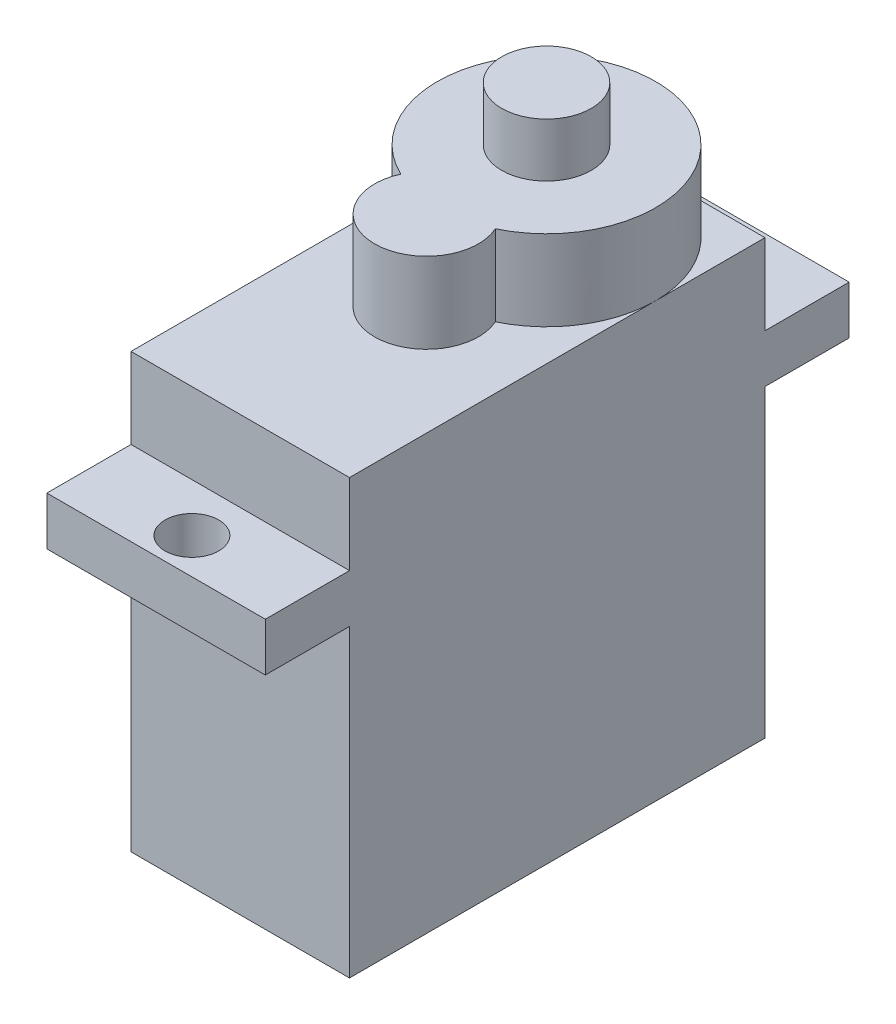
from build123d import *

# Parameters (mm, degrees)
SKETCH1_W           = 12.2
SKETCH1_H           = 23.2
BOSS_EXTRUDE3_DEPTH = 24.2
SKETCH5_W           = 12.2
SKETCH5_H           = 2.7
BOSS_EXTRUDE4_DEPTH = 4.7
CUT_EXTRUDE4_START  = -20.7
SKETCH6_R           = 1.5
CUT_EXTRUDE4_DEPTH  = 26.2
SKETCH7_R           = 2.9
SKETCH7_R_2         = 6.1
BOSS_EXTRUDE5_DEPTH = 4.5
SKETCH8_R           = 2.5
BOSS_EXTRUDE6_DEPTH = 3


with BuildPart() as part:
    # Sketch1 → Boss-Extrude3 (new body)
    with BuildSketch(Plane(origin=(0, 0, 0), x_dir=(1, 0, 0), z_dir=(0, 1, 0))):
        Rectangle(SKETCH1_W, SKETCH1_H)
    extrude(amount=BOSS_EXTRUDE3_DEPTH)

    # Sketch5 → Boss-Extrude4 (add)
    with BuildSketch(Plane.XY.offset(11.6)):
        with Locations((0, 18.35)):
            Rectangle(SKETCH5_W, SKETCH5_H)
    boss_extrude4 = extrude(amount=BOSS_EXTRUDE4_DEPTH)

    # Sketch6 → Cut-Extrude4 (cut)
    with BuildSketch(Plane(origin=(0, 19.7, 0), x_dir=(1, 0, 0), z_dir=(0, 1, 0)).offset(CUT_EXTRUDE4_START)):
        with Locations((0, -14.3)):
            Circle(SKETCH6_R)
    cut_extrude4 = extrude(amount=CUT_EXTRUDE4_DEPTH, mode=Mode.SUBTRACT)

    # Mirror3: Boss-Extrude4, Cut-Extrude4 across plane
    add(boss_extrude4.mirror(Plane.XY))
    add(cut_extrude4.mirror(Plane.XY), mode=Mode.SUBTRACT)

    # Sketch7 → Boss-Extrude5 (add)
    with BuildSketch(Plane(origin=(0, 24.2, 0), x_dir=(1, 0, 0), z_dir=(0, 1, 0))):
        with Locations((0, -1.2)):
            Circle(SKETCH7_R)
        with Locations((0, 5.5)):
            Circle(SKETCH7_R_2)
    extrude(amount=BOSS_EXTRUDE5_DEPTH)

    # Sketch8 → Boss-Extrude6 (add)
    with BuildSketch(Plane(origin=(0, 28.7, 0), x_dir=(1, 0, 0), z_dir=(0, 1, 0))):
        with Locations((0, 5.5)):
            Circle(SKETCH8_R)
    extrude(amount=BOSS_EXTRUDE6_DEPTH)


solid = part.part
